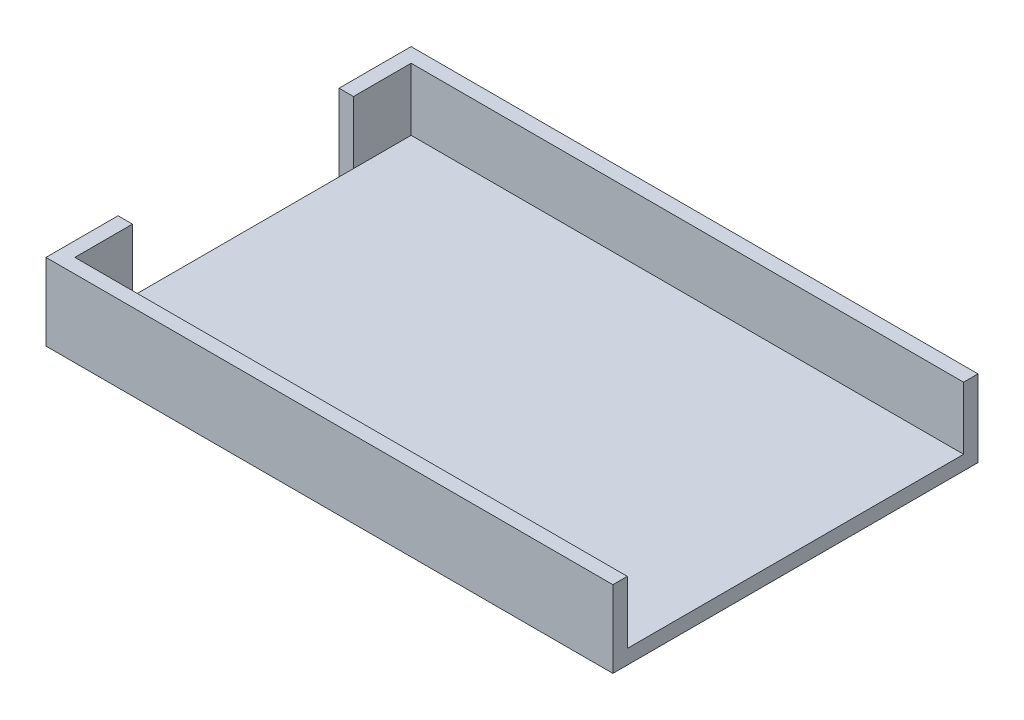
from build123d import *

# Parameters (mm, degrees)
SKETCH1_W           = 182.5625
SKETCH1_H           = 111.125
BOSS_EXTRUDE1_DEPTH = 4.7625
BOSS_EXTRUDE2_DEPTH = 25.4


with BuildPart() as part:
    # Sketch1 → Boss-Extrude1 (new body)
    with BuildSketch(Plane(origin=(0, 0, 0), x_dir=(1, 0, 0), z_dir=(0, 1, 0))):
        with Locations((9.695676813, -15.715633096)):
            Rectangle(SKETCH1_W, SKETCH1_H)
    extrude(amount=BOSS_EXTRUDE1_DEPTH)

    # Sketch3 → Boss-Extrude2 (add)
    with BuildSketch(Plane.XZ):
        Polygon((-86.348073187, -39.846866904), (-86.348073187, -20.796866904), (-81.585573187, -20.796866904), (-81.585573187, -39.846866904), (100.976926813, -39.846866904), (100.976926813, -44.609366904), (-86.348073187, -44.609366904), align=None)
        Polygon((-86.348073187, 71.278133096), (-86.348073187, 52.228133096), (-81.585573187, 52.228133096), (-81.585573187, 71.278133096), (100.976926813, 71.278133096), (100.976926813, 76.040633096), (-81.585573187, 76.040633096), (-86.348073187, 76.040633096), align=None)
    extrude(amount=-BOSS_EXTRUDE2_DEPTH)


solid = part.part
